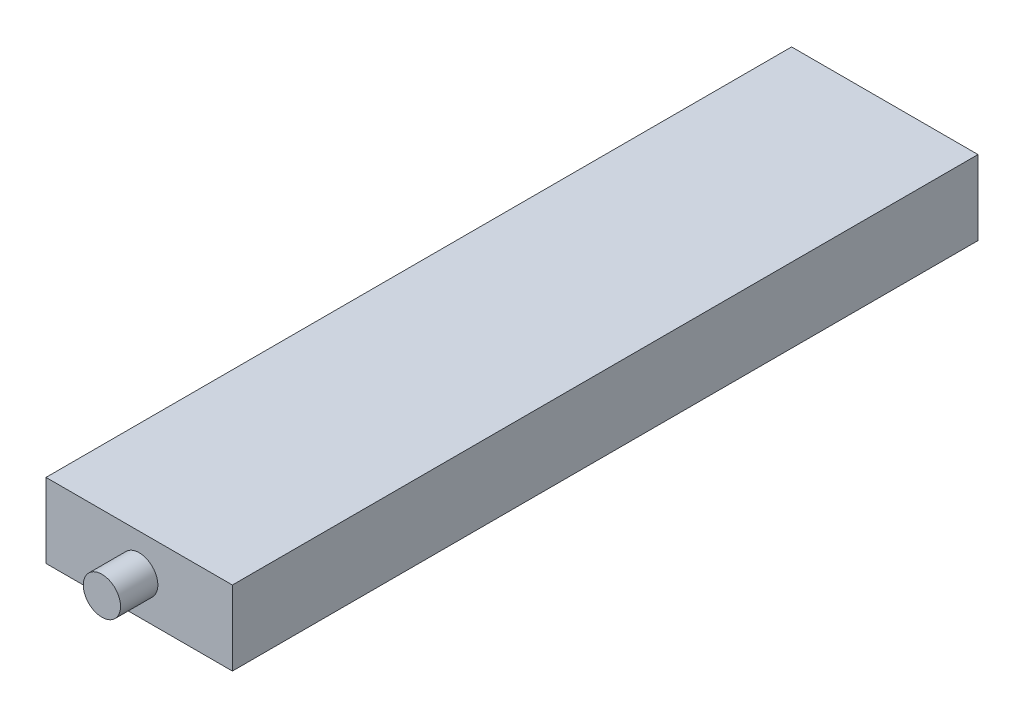
from build123d import *

# Parameters (mm, degrees)
SKETCH_1_W      = 50
SKETCH_1_H      = 200
EXTRUDE_1_DEPTH = 10
SKETCH_2_R      = 5
EXTRUDE_2_DEPTH = 10


with BuildPart() as part:
    # 草图1 → 凸台-拉伸1 (new body, symmetric)
    with BuildSketch(Plane(origin=(0, 0, 0), x_dir=(1, 0, 0), z_dir=(0, 1, 0))):
        with Locations((25, -100)):
            Rectangle(SKETCH_1_W, SKETCH_1_H)
    extrude(amount=EXTRUDE_1_DEPTH, both=True)

    # 草图2 → 凸台-拉伸2 (add, symmetric)
    with BuildSketch(Plane.XY.offset(200)):
        with Locations((25, 0)):
            Circle(SKETCH_2_R)
    extrude(amount=EXTRUDE_2_DEPTH, both=True)


solid = part.part
